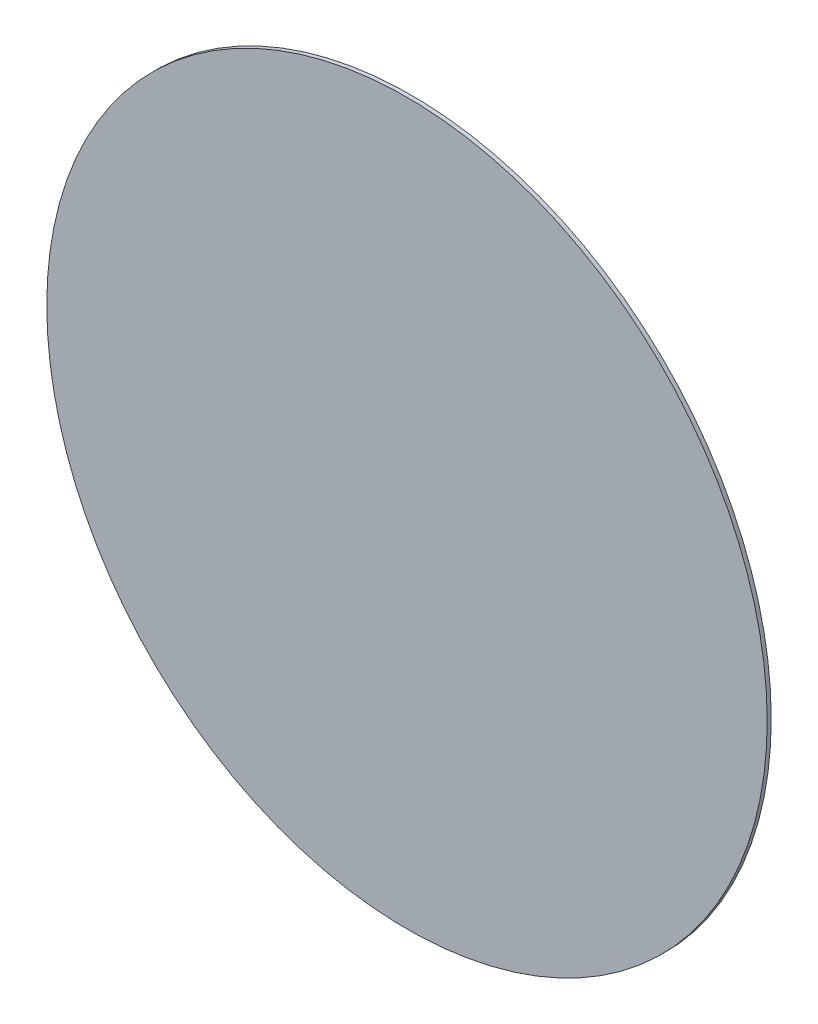
from build123d import *

# Parameters (mm, degrees)
SKETCH1_R           = 8.89
BOSS_EXTRUDE1_DEPTH = 0.09921875


with BuildPart() as part:
    # Sketch1 → Boss-Extrude1 (new body)
    with BuildSketch(Plane.XY):
        Circle(SKETCH1_R)
    extrude(amount=BOSS_EXTRUDE1_DEPTH)


solid = part.part
